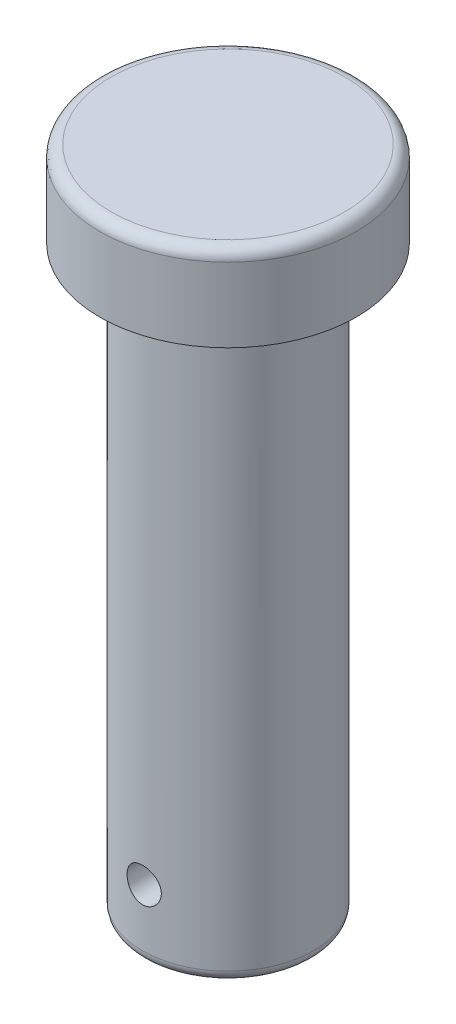
from build123d import *

# Parameters (mm, degrees)
SKETCH1_R               = 22.5
BOSS_EXTRUDE1_DEPTH     = 15
SKETCH2_R               = 15
BOSS_EXTRUDE2_DEPTH     = 102
FILLET1_R               = 2
SKETCH3_R               = 3
CUT_EXTRUDE1_DEPTH      = 23.5
CUT_EXTRUDE1_DEPTH_BACK = 23.5


with BuildPart() as part:
    # Sketch1 → Boss-Extrude1 (new body)
    with BuildSketch(Plane(origin=(0, 0, 0), x_dir=(1, 0, 0), z_dir=(0, 1, 0))):
        Circle(SKETCH1_R)
    extrude(amount=BOSS_EXTRUDE1_DEPTH)

    # Sketch2 → Boss-Extrude2 (add)
    with BuildSketch(Plane.XZ):
        Circle(SKETCH2_R)
    extrude(amount=BOSS_EXTRUDE2_DEPTH)

    # Fillet1
    fillet1_edges = [part.edges().sort_by_distance(p)[0] for p in [
        (-22.5, 15, 0),
        (-15, 0, 0),
        (-15, -102, 0),
    ]]
    fillet(fillet1_edges, radius=FILLET1_R)

    # Sketch3 → Cut-Extrude1 (cut, two sides)
    with BuildSketch(Plane.XY) as cut_extrude1_sk:
        with Locations((0, -90)):
            Circle(SKETCH3_R)
    extrude(amount=CUT_EXTRUDE1_DEPTH, mode=Mode.SUBTRACT)
    extrude(cut_extrude1_sk.sketch, amount=-CUT_EXTRUDE1_DEPTH_BACK, mode=Mode.SUBTRACT)


solid = part.part
